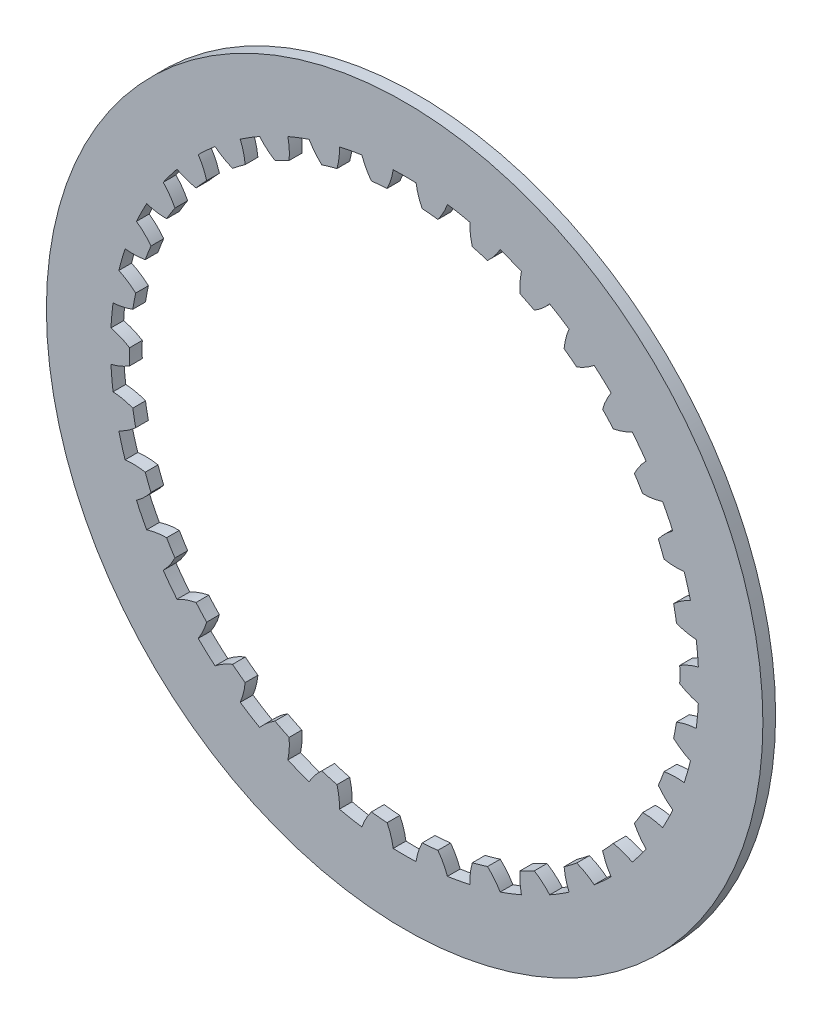
from build123d import *

# Parameters (mm, degrees)
SKETCH9_R           = 54.92
BOSS_EXTRUDE7_DEPTH = 1.95
CUT_EXTRUDE3_DEPTH  = 2.95
CIRPATTERN1_COUNT   = 34
SKETCH12_R          = 42.185
CUT_EXTRUDE4_DEPTH  = 2.95


with BuildPart() as part:
    # Sketch9 → Boss-Extrude7 (new body)
    with BuildSketch(Plane.XY):
        Circle(SKETCH9_R)
    extrude(amount=BOSS_EXTRUDE7_DEPTH)

    # Sketch10 → Cut-Extrude3 (cut, through all)
    with BuildSketch(Plane.XY.offset(1.95)):
        with BuildLine():
            ThreePointArc((-1.75, 45.051023573), (-2.102577815, 43.538839302), (-2.685, 42.099465555))
            ThreePointArc((-2.685, 42.099465555), (0, 42.185), (2.685, 42.099465555))
            ThreePointArc((2.685, 42.099465555), (2.102577815, 43.538839302), (1.75, 45.051023573))
            ThreePointArc((1.75, 45.051023573), (0, 45.085), (-1.75, 45.051023573))
        make_face()
    cut_extrude3 = extrude(amount=-CUT_EXTRUDE3_DEPTH, mode=Mode.SUBTRACT)

    # CirPattern1: Cut-Extrude3 ×34 about axis
    cirpattern1_axis = Axis((0, 0, 0), (0, 0, 1))
    for i in range(1, CIRPATTERN1_COUNT):
        add(cut_extrude3.rotate(cirpattern1_axis, i * 360 / CIRPATTERN1_COUNT), mode=Mode.SUBTRACT)

    # Sketch12 → Cut-Extrude4 (cut, through all)
    with BuildSketch(Plane.XY.offset(1.95)):
        Circle(SKETCH12_R)
    extrude(amount=-CUT_EXTRUDE4_DEPTH, mode=Mode.SUBTRACT)


solid = part.part
